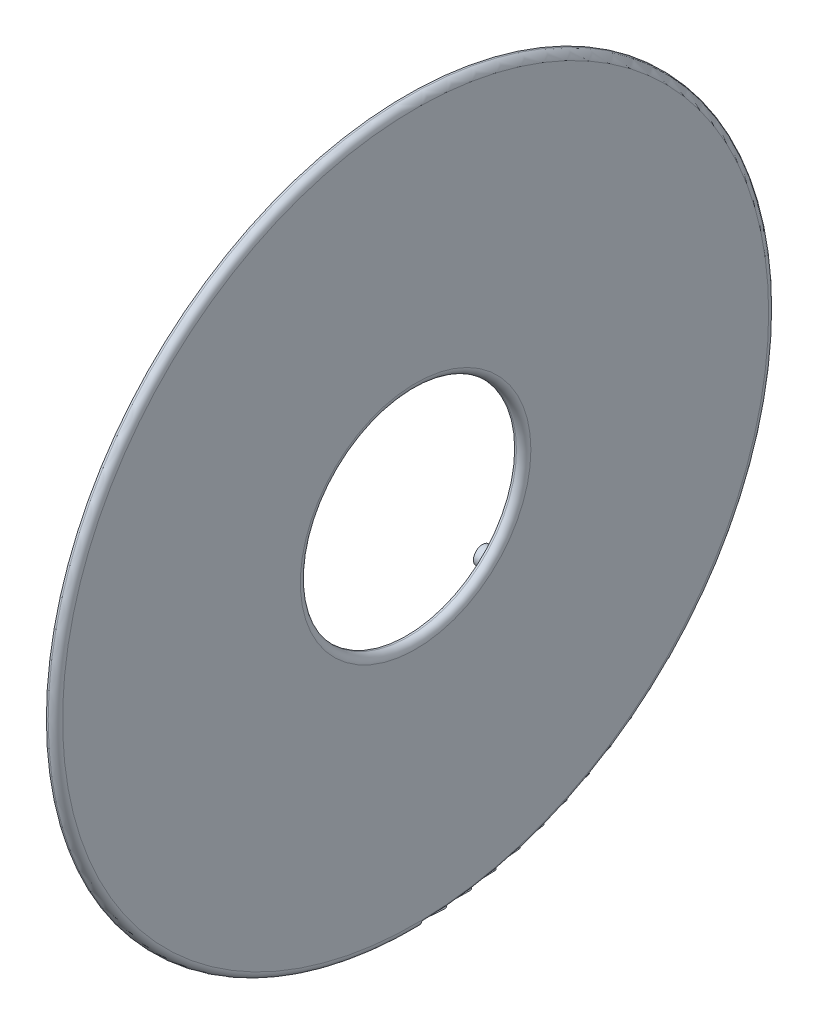
from build123d import *

# Parameters (mm, degrees)
SKETCH1_R           = 25.4
SKETCH1_R_2         = 7.62
BOSS_EXTRUDE1_DEPTH = 0.635
FILLET1_R           = 0.508
SKETCH2_R           = 0.635
BOSS_EXTRUDE2_DEPTH = 2.286


with BuildPart() as part:
    # Sketch1 → Boss-Extrude1 (new body)
    with BuildSketch(Plane(origin=(0, 0, 0), x_dir=(0, 0, -1), z_dir=(1, 0, 0))):
        Circle(SKETCH1_R)
        Circle(SKETCH1_R_2, mode=Mode.SUBTRACT)
    extrude(amount=BOSS_EXTRUDE1_DEPTH)

    # Fillet1
    fillet1_edges = [part.edges().sort_by_distance(p)[0] for p in [
        (0.635, 0, 25.4),
        (0.635, 0, 7.62),
    ]]
    fillet(fillet1_edges, radius=FILLET1_R)

    # Sketch2 → Boss-Extrude2 (add)
    with BuildSketch(Plane.ZY):
        with Locations((-7.633217703, 7.633217703)):
            Circle(SKETCH2_R)
        with Locations((7.633217703, 7.633217703)):
            Circle(SKETCH2_R)
        with Locations((7.633217703, -7.633217703)):
            Circle(SKETCH2_R)
        with Locations((-7.633217703, -7.633217703)):
            Circle(SKETCH2_R)
    extrude(amount=BOSS_EXTRUDE2_DEPTH)


solid = part.part
